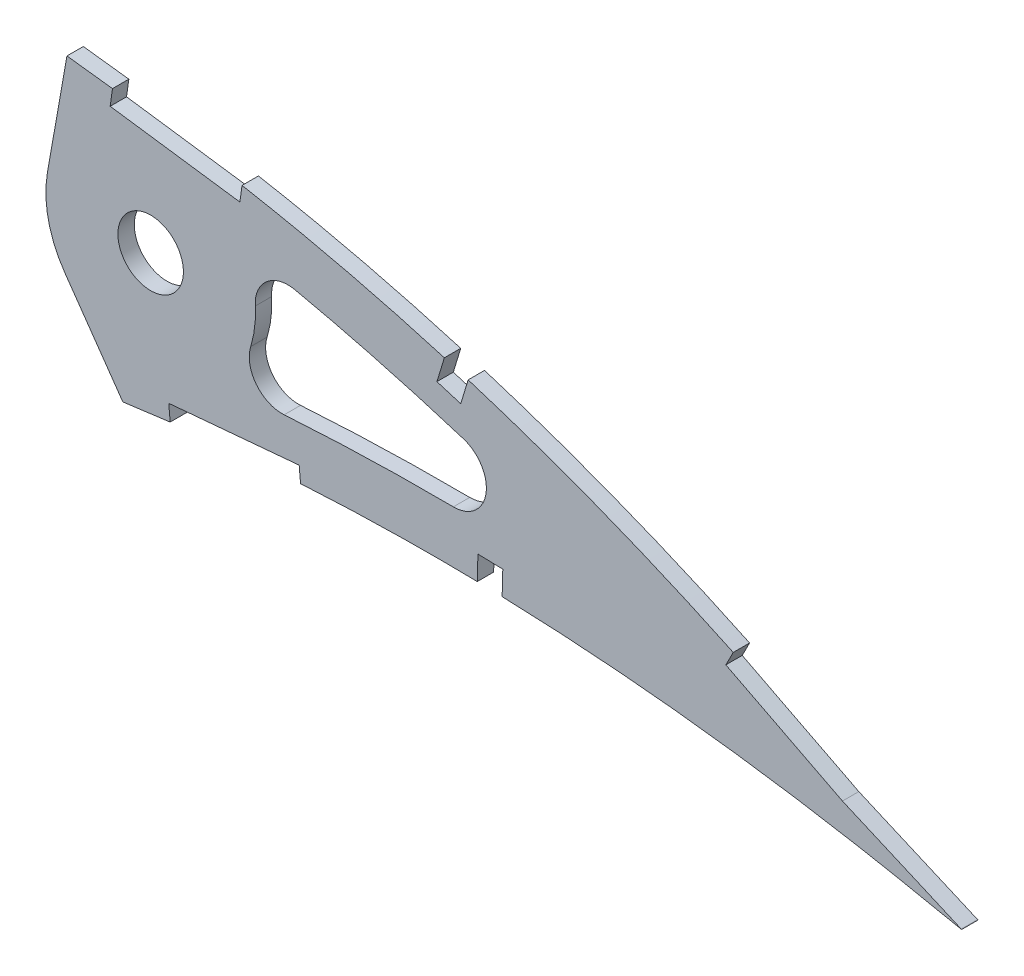
from build123d import *

# Parameters (mm, degrees)
BOSS_EXTRUDE1_DEPTH = 3.175
CUT_EXTRUDE3_DEPTH  = 7.62
CUT_EXTRUDE4_DEPTH  = 7.62
FILLET1_R           = 6.35


with BuildPart() as part:
    # Sketch1 → Boss-Extrude1 (new body)
    with BuildSketch(Plane.XY):
        with BuildLine():
            Line((519.580178516, -0.811051185), (524.404942797, -1.768650656))
            Line((524.404942797, -1.768650656), (520.229019484, 0.811051185))
            add(Edge.make_bspline(
                [(520.229019484, 0.811051185), (520.189166605, 0.835670541), (520.029909792, 0.934052399), (519.671075297, 1.154156729), (519.073541109, 1.52075127), (518.237045599, 2.031290225), (517.162238007, 2.684417324), (515.848577801, 3.475559373), (514.296885216, 4.402146321), (512.507535633, 5.459795421), (510.480712337, 6.64355473), (508.21718701, 7.948628257), (505.717156954, 9.367627965), (502.981590452, 10.894755239), (500.011426026, 12.522747531), (496.807225449, 14.244251548), (493.37013628, 16.050511122), (489.701477824, 17.933756977), (485.801919013, 19.88358962), (481.673298347, 21.891894303), (477.316991217, 23.948657398), (472.734484625, 26.042905917), (467.928411224, 28.166102482), (462.900099753, 30.30504754), (457.652415647, 32.45047346), (452.187593096, 34.590170691), (446.508867721, 36.714394111), (440.618430338, 38.809382682), (434.52068427, 40.865980983), (428.218587641, 42.870829), (421.71664718, 44.813038248), (415.018640596, 46.680016502), (408.130151416, 48.4621889), (401.05554842, 50.146576673), (393.800827801, 51.721905645), (386.37175624, 53.178690862), (378.7745642, 54.502388693), (371.03030434, 55.691966852), (363.263579962, 56.681494561), (355.512835044, 57.651994424), (347.773632806, 58.563690257), (339.939841334, 59.436765181), (332.018997168, 60.266303487), (324.018957152, 61.049711288), (315.947820171, 61.783607472), (307.813973652, 62.465839869), (299.625288266, 63.092542591), (291.390398495, 63.662750235), (283.117445562, 64.171449818), (274.815241205, 64.618259557), (266.492213302, 65.000063177), (258.157023363, 65.314229919), (249.818522106, 65.558863312), (241.485365181, 65.731619671), (233.166575282, 65.831412809), (224.870805251, 65.855515939), (216.607073574, 65.803497941), (208.384033719, 65.673572684), (200.210713382, 65.463961556), (192.095777843, 65.174273359), (184.048002143, 64.804633746), (176.076197788, 64.351947189), (168.189012741, 63.819098613), (160.39523005, 63.203849575), (152.703412853, 62.5060365), (145.121622257, 61.728568125), (137.65829938, 60.86932984), (130.321442651, 59.930766435), (123.119077117, 58.914718085), (116.059284027, 57.820631377), (109.149625996, 56.651666482), (102.397560522, 55.409019412), (95.81023125, 54.096333304), (89.394810054, 52.713950514), (83.158087983, 51.266017865), (77.106546628, 49.75505799), (71.246691254, 48.18383703), (65.58446207, 46.556125144), (60.125584795, 44.875615234), (54.876423204, 43.144153764), (49.840944503, 41.368305654), (45.025334256, 39.549331576), (40.433281375, 37.692835265), (36.070167381, 35.80135162), (31.939251719, 33.880646801), (28.045209615, 31.932907511), (24.39081638, 29.963590665), (20.979740738, 27.975715944), (17.815266227, 25.972975661), (14.898722839, 23.96044987), (12.234131686, 21.939401784), (9.822408113, 19.914938493), (7.665078309, 17.890142748), (5.765226023, 15.866409302), (4.122782784, 13.847302025), (2.739901149, 11.834419923), (1.61682102, 9.829667672), (0.75608259, 7.834501578), (0.156832386, 5.85004365), (-0.171193188, 3.879222922), (-0.252840734, 1.920459398), (-0.084154315, 0.639196632), (0, 0)],
                knots=[0, 0, 0, 0, 0.00025409, 0.001015373, 0.002283359, 0.004056577, 0.006330982, 0.009105275, 0.012374489, 0.016134023, 0.02037966, 0.025105976, 0.030306237, 0.035972206, 0.042099522, 0.048678064, 0.055701664, 0.063160184, 0.071045824, 0.079349826, 0.08806291, 0.097175757, 0.106678112, 0.116561573, 0.126814276, 0.1374283, 0.148393618, 0.15969976, 0.171338126, 0.183297699, 0.195569604, 0.208143556, 0.221011593, 0.234161831, 0.24758745, 0.261276822, 0.27522271, 0.289414144, 0.3037712, 0.317689227, 0.331784111, 0.346039677, 0.36044387, 0.374982721, 0.389640455, 0.404403317, 0.419256601, 0.434186749, 0.449177265, 0.464214782, 0.479284009, 0.49436974, 0.509457833, 0.524532346, 0.53957932, 0.554582984, 0.569529546, 0.584403417, 0.599190992, 0.613876838, 0.628447475, 0.642888675, 0.657186054, 0.671325546, 0.685294014, 0.699078147, 0.712665095, 0.726042645, 0.739197713, 0.752117586, 0.764792042, 0.777208152, 0.789355685, 0.80122396, 0.812803686, 0.824082909, 0.835054602, 0.845709571, 0.856037853, 0.866033834, 0.875688843, 0.884997719, 0.893953426, 0.902552897, 0.910789386, 0.918660734, 0.926166253, 0.933302626, 0.94007122, 0.94647478, 0.952517526, 0.958204819, 0.963546652, 0.9685566, 0.973249913, 0.977651041, 0.981787043, 0.985694226, 0.989415109, 0.993001157, 0.996508416, 1, 1, 1, 1], degree=3))
            add(Edge.make_bspline(
                [(0, 0), (0.133592971, -0.630647919), (0.401392883, -1.8948421), (1.12897029, -3.714757932), (2.091156676, -5.464224213), (3.308146123, -7.138593951), (4.771846833, -8.737409521), (6.479026026, -10.262333902), (8.42800953, -11.712547121), (10.616246406, -13.087389262), (13.040557967, -14.388319695), (15.69821927, -15.614529628), (18.58680706, -16.765635887), (21.703174164, -17.840099654), (25.043510698, -18.839557444), (28.604640883, -19.761573512), (32.382515332, -20.607436647), (36.373500457, -21.374987622), (40.573247311, -22.065006311), (44.977392966, -22.677106427), (49.581416855, -23.211670923), (54.380802091, -23.667578066), (59.370801609, -24.045808466), (64.546441805, -24.346612989), (69.902698778, -24.570945614), (75.434441794, -24.717953346), (81.136253147, -24.789928223), (87.002979994, -24.787950681), (93.028883282, -24.711491768), (99.208815464, -24.564775433), (105.536846201, -24.346872236), (112.007262561, -24.060419153), (118.614228145, -23.708298892), (125.351817225, -23.291705179), (132.214100493, -22.812484346), (139.195119589, -22.274479418), (146.288532921, -21.679032497), (153.488154076, -21.029614162), (160.787609185, -20.329475604), (168.180591644, -19.580832593), (175.660575836, -18.787206853), (183.220899465, -17.951170059), (190.855131019, -17.077182461), (198.556296664, -16.166825422), (206.317884213, -15.225296547), (214.132591981, -14.254394805), (221.993885293, -13.257859815), (229.894693671, -12.240383742), (237.827620604, -11.201850487), (245.785993956, -10.149659277), (253.762138918, -9.082943465), (261.749112783, -8.007189221), (269.739522148, -6.925740253), (277.725584215, -5.838929488), (285.70027901, -4.751260828), (293.656208576, -3.665720235), (301.585579958, -2.582406874), (309.481219182, -1.506705212), (317.335175518, -0.438483792), (325.140206955, 0.620091626), (332.888833934, 1.665861231), (340.573746099, 2.697505345), (348.187015915, 3.714371056), (355.720983847, 4.716840325), (363.055280122, 5.674485749), (370.170740115, 6.638302095), (377.091341637, 7.428417974), (383.925772848, 8.102810237), (390.681133097, 8.655718896), (397.349310673, 9.095098533), (403.922665289, 9.424088714), (410.393362863, 9.647282626), (416.753229966, 9.771301523), (422.994322965, 9.799292754), (429.108122993, 9.740182902), (435.086678505, 9.598736647), (440.921645401, 9.381302955), (446.604883368, 9.095217537), (452.128319892, 8.748279397), (457.483662622, 8.34560601), (462.663449177, 7.896598156), (467.65968785, 7.407828642), (472.464706853, 6.884881883), (477.071494939, 6.338715544), (481.472678479, 5.77292572), (485.661637464, 5.196810252), (489.631628754, 4.616207627), (493.376364947, 4.038530197), (496.889962423, 3.469289139), (500.16674573, 2.91603967), (503.201581909, 2.38395084), (505.989204715, 1.878219093), (508.525746868, 1.40522509), (510.806198597, 0.967318665), (512.827510034, 0.571716412), (514.585922757, 0.220164109), (516.078859088, -0.082385429), (517.303711765, -0.334738039), (518.258620558, -0.532751237), (518.941699265, -0.676741413), (519.352209069, -0.762422848), (519.534603778, -0.801329602), (519.580178516, -0.811051185)],
                knots=[0, 0, 0, 0, 0.003638255, 0.007293231, 0.011028136, 0.014901081, 0.018963272, 0.023258475, 0.027820626, 0.032679082, 0.03785316, 0.043361875, 0.049214679, 0.055422346, 0.061988786, 0.068918036, 0.076211157, 0.083868392, 0.091887411, 0.100265912, 0.108999867, 0.118084529, 0.127514843, 0.13728527, 0.147387917, 0.157816481, 0.168563473, 0.179619128, 0.190977373, 0.202626974, 0.214560478, 0.226767249, 0.239236417, 0.251959004, 0.264923894, 0.278119703, 0.291536035, 0.30516028, 0.318980685, 0.332985499, 0.34716279, 0.361498603, 0.375980747, 0.390597192, 0.405332593, 0.420174823, 0.435109533, 0.450124276, 0.465203068, 0.480333154, 0.495500583, 0.510689775, 0.525887334, 0.541078314, 0.556247233, 0.571381784, 0.586466041, 0.601484516, 0.616424329, 0.631269422, 0.646006524, 0.660620684, 0.675098188, 0.689422858, 0.703581825, 0.716907564, 0.730009274, 0.742952128, 0.755725558, 0.768319952, 0.780724337, 0.792926529, 0.804916041, 0.816679084, 0.828203524, 0.8394749, 0.850481359, 0.861207697, 0.871639326, 0.881763414, 0.891563605, 0.901027364, 0.910138977, 0.918883976, 0.927249278, 0.935221104, 0.942784739, 0.949928188, 0.956638464, 0.962904203, 0.968712287, 0.974054485, 0.978918432, 0.983297219, 0.987180246, 0.990560674, 0.993433357, 0.995790625, 0.997629587, 0.998945816, 0.999736592, 1, 1, 1, 1], degree=3))
        make_face()
    extrude(amount=BOSS_EXTRUDE1_DEPTH)

    # Sketch4 → Cut-Extrude3 (cut)
    with BuildSketch(Plane(origin=(0, 0, 0), x_dir=(-1, 0, 0), z_dir=(0, 0, -1))):
        with BuildLine():
            Line((-349.14248935, 48.169354496), (-347.130907312, 36.761105856))
            ThreePointArc((-347.130907312, 36.761105856), (-346.899524588, 35.003579579), (-346.822200854, 33.232574886))
            ThreePointArc((-346.822200854, 33.232574886), (-347.762672414, 27.12223304), (-350.497031314, 21.577501699))
            Line((-350.497031314, 21.577501699), (-355.179580356, 14.890128618))
            add(Edge.make_bspline(
                [(-10.021983668, 1.718504447), (-10.07412361, 1.477650445), (-10.114944509, 1.303174971), (-10.156548889, 1.141436943), (-10.167021522, 1.104153089), (-10.176316559, 1.072542508), (-10.178069379, 1.066836035), (-10.183484597, 1.049711185), (-10.186673858, 1.039927229), (-10.205238412, 0.98502642), (-10.228571307, 0.921908681), (-10.27906945, 0.80173784), (-10.298464439, 0.7574435), (-10.342612759, 0.661010339), (-10.367571751, 0.608494082), (-10.442823867, 0.45606075), (-10.495986254, 0.355803747), (-10.608102234, 0.158407972), (-10.666162883, 0.06265551), (-10.854968465, -0.229090809), (-11.00643436, -0.438409454), (-11.537771942, -1.093588654), (-11.997135293, -1.567704333), (-13.099028095, -2.52560338), (-13.741234272, -3.010007667), (-15.170231039, -3.956772652), (-15.958792546, -4.420759041), (-17.636020893, -5.30935855), (-18.526216751, -5.735132845), (-21.309408713, -6.950344824), (-23.307276982, -7.674934635), (-27.46702649, -8.97576354), (-29.622936527, -9.549686743), (-34.031579145, -10.575277046), (-36.279538408, -11.025153664), (-40.839010815, -11.824269496), (-43.147104248, -12.172849285), (-47.803539587, -12.786210538), (-50.150083972, -13.050814849), (-57.229184321, -13.737294833), (-62.003016189, -14.054069855), (-71.598509018, -14.480928375), (-76.421961843, -14.589122052), (-83.681580342, -14.632442814), (-86.103710065, -14.626756009), (-90.955097909, -14.578941965), (-93.385559609, -14.537119349), (-100.67932715, -14.364677341), (-105.548006485, -14.185375883), (-120.177304443, -13.493946775), (-129.947568603, -12.830040027), (-149.500900247, -11.230052761), (-159.28699099, -10.293590446), (-178.862979206, -8.239223166), (-188.653155316, -7.120306209), (-203.345768331, -5.354247594), (-208.242397067, -4.751052701), (-218.038698444, -3.520719007), (-222.939495496, -2.894332575), (-232.735865431, -1.624265185), (-237.638546286, -0.979500709), (-247.439293316, 0.320232313), (-252.34040524, 0.977351243), (-262.147002187, 2.298643123), (-267.049997176, 2.962506366), (-276.85767651, 4.296404336), (-281.76413014, 4.965872948), (-291.576776525, 6.304693949), (-296.482463455, 6.975228249), (-306.300679591, 8.314190148), (-311.208735298, 8.982245452), (-325.937797656, 10.98262524), (-335.765990201, 12.306839554), (-348.046657919, 13.945065226), (-350.503930711, 14.272529112), (-353.703483298, 14.695680718), (-354.441892389, 14.793034628), (-355.179580356, 14.890128618)],
                knots=[0, 0, 0, 0, 0.001953125, 0.001953125, 0.002929688, 0.002929688, 0.003417969, 0.003417969, 0.00390625, 0.00390625, 0.005859375, 0.005859375, 0.006835938, 0.006835938, 0.0078125, 0.0078125, 0.009765625, 0.009765625, 0.01171875, 0.01171875, 0.015625, 0.015625, 0.0234375, 0.0234375, 0.03125, 0.03125, 0.0390625, 0.0390625, 0.046875, 0.046875, 0.0625, 0.0625, 0.078125, 0.078125, 0.09375, 0.09375, 0.109375, 0.109375, 0.125, 0.125, 0.15625, 0.15625, 0.1875, 0.1875, 0.203125, 0.203125, 0.21875, 0.21875, 0.25, 0.25, 0.3125, 0.3125, 0.375, 0.375, 0.4375, 0.4375, 0.46875, 0.46875, 0.5, 0.5, 0.53125, 0.53125, 0.5625, 0.5625, 0.59375, 0.59375, 0.625, 0.625, 0.65625, 0.65625, 0.6875, 0.6875, 0.75, 0.75, 0.765625, 0.765625, 0.770309007, 0.770309007, 0.770309007, 0.770309007], degree=3))
            add(Edge.make_bspline(
                [(-349.14248935, 48.169354496), (-346.795088799, 48.443461283), (-344.445266437, 48.710791614), (-339.547708643, 49.253693934), (-336.999317609, 49.527914022), (-329.351218513, 50.325591781), (-324.249629568, 50.824187172), (-308.936798872, 52.217367234), (-298.717604439, 53.010707627), (-278.271746609, 54.303919673), (-268.04058752, 54.805738268), (-247.580126149, 55.491327017), (-237.350101584, 55.675458898), (-216.900448668, 55.69215602), (-206.683126571, 55.52564041), (-191.377917358, 54.978478925), (-186.2811734, 54.747225516), (-176.097881874, 54.177019905), (-171.009883782, 53.839581001), (-160.853325764, 53.050443965), (-155.781406433, 52.598034279), (-145.657356086, 51.571992269), (-140.607230814, 50.997094398), (-125.489247663, 49.071048015), (-115.464585248, 47.521419143), (-100.554676791, 44.706390499), (-95.609568485, 43.686963586), (-85.777014674, 41.462020045), (-80.892152382, 40.257818542), (-71.207221082, 37.636651206), (-66.406776713, 36.220917836), (-59.302413791, 33.90898455), (-56.947363109, 33.106291256), (-52.282107957, 31.434331217), (-49.969322239, 30.563571343), (-45.392720502, 28.745833214), (-43.131848477, 27.799594329), (-38.671512861, 25.819641246), (-36.476017636, 24.788163994), (-32.175786858, 22.628129157), (-30.06919395, 21.499499767), (-27.012454773, 19.728422083), (-26.01030714, 19.124661313), (-24.046433441, 17.888999014), (-23.083087936, 17.256148879), (-21.212769006, 15.965886334), (-20.304850458, 15.30761594), (-18.553368516, 13.962900236), (-17.709326175, 13.276269337), (-16.108143733, 11.882352161), (-15.351929118, 11.17596838), (-14.304534439, 10.110877651), (-13.970137373, 9.755237813), (-13.332516445, 9.043077516), (-13.02962733, 8.686953168), (-12.180304935, 7.629928767), (-11.689567714, 6.934793852), (-10.890562918, 5.612793643), (-10.587398477, 4.993614778), (-10.268976897, 4.158008466), (-10.186143047, 3.89687765), (-10.09533528, 3.545881825), (-10.070664667, 3.436625129), (-10.026694338, 3.210393083), (-10.008058479, 3.095951038), (-9.977689614, 2.864928598), (-9.965765536, 2.743795853), (-9.952900238, 2.554662515), (-9.951205484, 2.481144388), (-9.951588775, 2.417814084), (-9.951784603, 2.406570209), (-9.952306257, 2.386954058), (-9.952564773, 2.379980569), (-9.953821763, 2.353767727), (-9.955956606, 2.318014253), (-9.969807564, 2.15543948), (-9.989590405, 1.973346258), (-10.021983668, 1.718504447)],
                knots=[0.251217482, 0.251217482, 0.251217482, 0.251217482, 0.265625, 0.265625, 0.28125, 0.28125, 0.3125, 0.3125, 0.375, 0.375, 0.4375, 0.4375, 0.5, 0.5, 0.5625, 0.5625, 0.59375, 0.59375, 0.625, 0.625, 0.65625, 0.65625, 0.6875, 0.6875, 0.75, 0.75, 0.78125, 0.78125, 0.8125, 0.8125, 0.84375, 0.84375, 0.859375, 0.859375, 0.875, 0.875, 0.890625, 0.890625, 0.90625, 0.90625, 0.921875, 0.921875, 0.9296875, 0.9296875, 0.9375, 0.9375, 0.9453125, 0.9453125, 0.953125, 0.953125, 0.9609375, 0.9609375, 0.96484375, 0.96484375, 0.96875, 0.96875, 0.9765625, 0.9765625, 0.984375, 0.984375, 0.98828125, 0.98828125, 0.990234375, 0.990234375, 0.9921875, 0.9921875, 0.994140625, 0.994140625, 0.99609375, 0.99609375, 0.996582031, 0.996582031, 0.997070313, 0.997070313, 0.998046875, 0.998046875, 1, 1, 1, 1], degree=3))
        make_face()
        with BuildLine():
            ThreePointArc((-360.792200854, 33.232574886), (-367.142200854, 39.582574886), (-373.492200854, 33.232574886))
            ThreePointArc((-373.492200854, 33.232574886), (-367.142200854, 26.882574886), (-360.792200854, 33.232574886))
        make_face()
        with BuildLine():
            Line((-350.909730833, 58.191878985), (-349.14248935, 48.169354496))
            add(Edge.make_bspline(
                [(-349.14248935, 48.169354496), (-346.795088799, 48.443461283), (-344.445266437, 48.710791614), (-339.547708643, 49.253693934), (-336.999317609, 49.527914022), (-329.351218513, 50.325591781), (-324.249629568, 50.824187172), (-308.936798872, 52.217367234), (-298.717604439, 53.010707627), (-278.271746609, 54.303919673), (-268.04058752, 54.805738268), (-247.580126149, 55.491327017), (-237.350101584, 55.675458898), (-216.900448668, 55.69215602), (-206.683126571, 55.52564041), (-191.377917358, 54.978478925), (-186.2811734, 54.747225516), (-176.097881874, 54.177019905), (-171.009883782, 53.839581001), (-160.853325764, 53.050443965), (-155.781406433, 52.598034279), (-145.657356086, 51.571992269), (-140.607230814, 50.997094398), (-125.489247663, 49.071048015), (-115.464585248, 47.521419143), (-100.554676791, 44.706390499), (-95.609568485, 43.686963586), (-85.777014674, 41.462020045), (-80.892152382, 40.257818542), (-71.207221082, 37.636651206), (-66.406776713, 36.220917836), (-59.302413791, 33.90898455), (-56.947363109, 33.106291256), (-52.282107957, 31.434331217), (-49.969322239, 30.563571343), (-45.392720502, 28.745833214), (-43.131848477, 27.799594329), (-38.671512861, 25.819641246), (-36.476017636, 24.788163994), (-32.175786858, 22.628129157), (-30.06919395, 21.499499767), (-27.012454773, 19.728422083), (-26.01030714, 19.124661313), (-24.046433441, 17.888999014), (-23.083087936, 17.256148879), (-21.212769006, 15.965886334), (-20.304850458, 15.30761594), (-18.553368516, 13.962900236), (-17.709326175, 13.276269337), (-16.108143733, 11.882352161), (-15.351929118, 11.17596838), (-14.304534439, 10.110877651), (-13.970137373, 9.755237813), (-13.332516445, 9.043077516), (-13.02962733, 8.686953168), (-12.180304935, 7.629928767), (-11.689567714, 6.934793852), (-10.890562918, 5.612793643), (-10.587398477, 4.993614778), (-10.268976897, 4.158008466), (-10.186143047, 3.89687765), (-10.09533528, 3.545881825), (-10.070664667, 3.436625129), (-10.026694338, 3.210393083), (-10.008058479, 3.095951038), (-9.977689614, 2.864928598), (-9.965765536, 2.743795853), (-9.952900238, 2.554662515), (-9.951205484, 2.481144388), (-9.951588775, 2.417814084), (-9.951784603, 2.406570209), (-9.952306257, 2.386954058), (-9.952564773, 2.379980569), (-9.953821763, 2.353767727), (-9.955956606, 2.318014253), (-9.969807564, 2.15543948), (-9.989590405, 1.973346258), (-10.021983668, 1.718504447)],
                knots=[0.251217482, 0.251217482, 0.251217482, 0.251217482, 0.265625, 0.265625, 0.28125, 0.28125, 0.3125, 0.3125, 0.375, 0.375, 0.4375, 0.4375, 0.5, 0.5, 0.5625, 0.5625, 0.59375, 0.59375, 0.625, 0.625, 0.65625, 0.65625, 0.6875, 0.6875, 0.75, 0.75, 0.78125, 0.78125, 0.8125, 0.8125, 0.84375, 0.84375, 0.859375, 0.859375, 0.875, 0.875, 0.890625, 0.890625, 0.90625, 0.90625, 0.921875, 0.921875, 0.9296875, 0.9296875, 0.9375, 0.9375, 0.9453125, 0.9453125, 0.953125, 0.953125, 0.9609375, 0.9609375, 0.96484375, 0.96484375, 0.96875, 0.96875, 0.9765625, 0.9765625, 0.984375, 0.984375, 0.98828125, 0.98828125, 0.990234375, 0.990234375, 0.9921875, 0.9921875, 0.994140625, 0.994140625, 0.99609375, 0.99609375, 0.996582031, 0.996582031, 0.997070313, 0.997070313, 0.998046875, 0.998046875, 1, 1, 1, 1], degree=3))
            add(Edge.make_bspline(
                [(-7.716509218, 17.89881351), (-8.627577305, 8.933677844), (-9.635591183, 3.50339667), (-10.021983668, 1.718504447)],
                knots=[-0.014473987, -0.014473987, -0.014473987, -0.014473987, 0, 0, 0, 0], degree=3))
            add(Edge.make_bspline(
                [(-350.909730833, 58.191878985), (-349.87402552, 58.313335631), (-346.227461312, 58.736010846), (-339.939841334, 59.436765181), (-332.018997168, 60.266303487), (-324.018957152, 61.049711288), (-315.947820171, 61.783607472), (-307.813973652, 62.465839869), (-299.625288266, 63.092542591), (-291.390398495, 63.662750235), (-283.117445562, 64.171449818), (-274.815241205, 64.618259557), (-266.492213302, 65.000063177), (-258.157023363, 65.314229919), (-249.818522106, 65.558863312), (-241.485365181, 65.731619671), (-233.166575282, 65.831412809), (-224.870805251, 65.855515939), (-216.607073574, 65.803497941), (-208.384033719, 65.673572684), (-200.210713382, 65.463961556), (-192.095777843, 65.174273359), (-184.048002143, 64.804633746), (-176.076197788, 64.351947189), (-168.189012741, 63.819098613), (-160.39523005, 63.203849575), (-152.703412853, 62.5060365), (-145.121622257, 61.728568125), (-137.65829938, 60.86932984), (-130.321442651, 59.930766435), (-123.119077117, 58.914718085), (-116.059284027, 57.820631377), (-109.149625996, 56.651666482), (-102.397560522, 55.409019412), (-95.81023125, 54.096333304), (-89.394810054, 52.713950514), (-83.158087983, 51.266017865), (-77.106546628, 49.75505799), (-71.246691254, 48.18383703), (-65.58446207, 46.556125144), (-60.125584795, 44.875615234), (-54.876423204, 43.144153764), (-49.840944503, 41.368305654), (-45.025334256, 39.549331576), (-40.433281375, 37.692835265), (-36.070167381, 35.80135162), (-31.939251719, 33.880646801), (-28.045209615, 31.932907511), (-24.39081638, 29.963590665), (-20.979740738, 27.975715944), (-17.815266227, 25.972975661), (-14.898722839, 23.96044987), (-12.234131686, 21.939401784), (-9.848909513, 19.937184455), (-8.389426027, 18.569945978), (-7.716509217, 17.89881351)],
                knots=[0.326127798, 0.326127798, 0.326127798, 0.326127798, 0.331784111, 0.346039677, 0.36044387, 0.374982721, 0.389640455, 0.404403317, 0.419256601, 0.434186749, 0.449177265, 0.464214782, 0.479284009, 0.49436974, 0.509457833, 0.524532346, 0.53957932, 0.554582984, 0.569529546, 0.584403417, 0.599190992, 0.613876838, 0.628447475, 0.642888675, 0.657186054, 0.671325546, 0.685294014, 0.699078147, 0.712665095, 0.726042645, 0.739197713, 0.752117586, 0.764792042, 0.777208152, 0.789355685, 0.80122396, 0.812803686, 0.824082909, 0.835054602, 0.845709571, 0.856037853, 0.866033834, 0.875688843, 0.884997719, 0.893953426, 0.902552897, 0.910789386, 0.918660734, 0.926166253, 0.933302626, 0.94007122, 0.94647478, 0.952517526, 0.958204819, 0.963359057, 0.963359057, 0.963359057, 0.963359057], degree=3))
        make_face()
        with BuildLine():
            add(Edge.make_bspline(
                [(-10.021983668, 1.718504447), (-10.253419541, -0.102230211), (-11.128552571, -5.636405878), (-13.399217815, -14.533387864)],
                knots=[1, 1, 1, 1, 1.013954234, 1.013954234, 1.013954234, 1.013954234], degree=3))
            add(Edge.make_bspline(
                [(-10.021983668, 1.718504447), (-10.07412361, 1.477650445), (-10.114944509, 1.303174971), (-10.156548889, 1.141436943), (-10.167021522, 1.104153089), (-10.176316559, 1.072542508), (-10.178069379, 1.066836035), (-10.183484597, 1.049711185), (-10.186673858, 1.039927229), (-10.205238412, 0.98502642), (-10.228571307, 0.921908681), (-10.27906945, 0.80173784), (-10.298464439, 0.7574435), (-10.342612759, 0.661010339), (-10.367571751, 0.608494082), (-10.442823867, 0.45606075), (-10.495986254, 0.355803747), (-10.608102234, 0.158407972), (-10.666162883, 0.06265551), (-10.854968465, -0.229090809), (-11.00643436, -0.438409454), (-11.537771942, -1.093588654), (-11.997135293, -1.567704333), (-13.099028095, -2.52560338), (-13.741234272, -3.010007667), (-15.170231039, -3.956772652), (-15.958792546, -4.420759041), (-17.636020893, -5.30935855), (-18.526216751, -5.735132845), (-21.309408713, -6.950344824), (-23.307276982, -7.674934635), (-27.46702649, -8.97576354), (-29.622936527, -9.549686743), (-34.031579145, -10.575277046), (-36.279538408, -11.025153664), (-40.839010815, -11.824269496), (-43.147104248, -12.172849285), (-47.803539587, -12.786210538), (-50.150083972, -13.050814849), (-57.229184321, -13.737294833), (-62.003016189, -14.054069855), (-71.598509018, -14.480928375), (-76.421961843, -14.589122052), (-83.681580342, -14.632442814), (-86.103710065, -14.626756009), (-90.955097909, -14.578941965), (-93.385559609, -14.537119349), (-100.67932715, -14.364677341), (-105.548006485, -14.185375883), (-120.177304443, -13.493946775), (-129.947568603, -12.830040027), (-149.500900247, -11.230052761), (-159.28699099, -10.293590446), (-178.862979206, -8.239223166), (-188.653155316, -7.120306209), (-203.345768331, -5.354247594), (-208.242397067, -4.751052701), (-218.038698444, -3.520719007), (-222.939495496, -2.894332575), (-232.735865431, -1.624265185), (-237.638546286, -0.979500709), (-247.439293316, 0.320232313), (-252.34040524, 0.977351243), (-262.147002187, 2.298643123), (-267.049997176, 2.962506366), (-276.85767651, 4.296404336), (-281.76413014, 4.965872948), (-291.576776525, 6.304693949), (-296.482463455, 6.975228249), (-306.300679591, 8.314190148), (-311.208735298, 8.982245452), (-325.937797656, 10.98262524), (-335.765990201, 12.306839554), (-348.046657919, 13.945065226), (-350.503930711, 14.272529112), (-353.703483298, 14.695680718), (-354.441892389, 14.793034628), (-355.179580356, 14.890128618)],
                knots=[0, 0, 0, 0, 0.001953125, 0.001953125, 0.002929688, 0.002929688, 0.003417969, 0.003417969, 0.00390625, 0.00390625, 0.005859375, 0.005859375, 0.006835938, 0.006835938, 0.0078125, 0.0078125, 0.009765625, 0.009765625, 0.01171875, 0.01171875, 0.015625, 0.015625, 0.0234375, 0.0234375, 0.03125, 0.03125, 0.0390625, 0.0390625, 0.046875, 0.046875, 0.0625, 0.0625, 0.078125, 0.078125, 0.09375, 0.09375, 0.109375, 0.109375, 0.125, 0.125, 0.15625, 0.15625, 0.1875, 0.1875, 0.203125, 0.203125, 0.21875, 0.21875, 0.25, 0.25, 0.3125, 0.3125, 0.375, 0.375, 0.4375, 0.4375, 0.46875, 0.46875, 0.5, 0.5, 0.53125, 0.53125, 0.5625, 0.5625, 0.59375, 0.59375, 0.625, 0.625, 0.65625, 0.65625, 0.6875, 0.6875, 0.75, 0.75, 0.765625, 0.765625, 0.770309007, 0.770309007, 0.770309007, 0.770309007], degree=3))
            Line((-355.179580356, 14.890128618), (-361.749554482, 5.507233166))
            add(Edge.make_bspline(
                [(-13.399217815, -14.533387864), (-14.141861653, -14.89580716), (-15.836050944, -15.669455742), (-18.58680706, -16.765635887), (-21.703174164, -17.840099654), (-25.043510698, -18.839557444), (-28.604640883, -19.761573512), (-32.382515332, -20.607436647), (-36.373500457, -21.374987622), (-40.573247311, -22.065006311), (-44.977392966, -22.677106427), (-49.581416855, -23.211670923), (-54.380802091, -23.667578066), (-59.370801609, -24.045808466), (-64.546441805, -24.346612989), (-69.902698778, -24.570945614), (-75.434441794, -24.717953346), (-81.136253147, -24.789928223), (-87.002979994, -24.787950681), (-93.028883282, -24.711491768), (-99.208815464, -24.564775433), (-105.536846201, -24.346872236), (-112.007262561, -24.060419153), (-118.614228145, -23.708298892), (-125.351817225, -23.291705179), (-132.214100493, -22.812484346), (-139.195119589, -22.274479418), (-146.288532921, -21.679032497), (-153.488154076, -21.029614162), (-160.787609185, -20.329475604), (-168.180591644, -19.580832593), (-175.660575836, -18.787206853), (-183.220899465, -17.951170059), (-190.855131019, -17.077182461), (-198.556296664, -16.166825422), (-206.317884213, -15.225296547), (-214.132591981, -14.254394805), (-221.993885293, -13.257859815), (-229.894693671, -12.240383742), (-237.827620604, -11.201850487), (-245.785993956, -10.149659277), (-253.762138918, -9.082943465), (-261.749112783, -8.007189221), (-269.739522148, -6.925740253), (-277.725584215, -5.838929488), (-285.70027901, -4.751260828), (-293.656208576, -3.665720235), (-301.585579958, -2.582406874), (-309.481219182, -1.506705212), (-317.335175518, -0.438483792), (-325.140206955, 0.620091626), (-332.888833934, 1.665861231), (-340.573746099, 2.697505345), (-348.187015915, 3.714371056), (-355.23730571, 4.652482144), (-359.750002253, 5.242796176), (-361.749554482, 5.507233166)],
                knots=[0.03869149, 0.03869149, 0.03869149, 0.03869149, 0.043361875, 0.049214679, 0.055422346, 0.061988786, 0.068918036, 0.076211157, 0.083868392, 0.091887411, 0.100265912, 0.108999867, 0.118084529, 0.127514843, 0.13728527, 0.147387917, 0.157816481, 0.168563473, 0.179619128, 0.190977373, 0.202626974, 0.214560478, 0.226767249, 0.239236417, 0.251959004, 0.264923894, 0.278119703, 0.291536035, 0.30516028, 0.318980685, 0.332985499, 0.34716279, 0.361498603, 0.375980747, 0.390597192, 0.405332593, 0.420174823, 0.435109533, 0.450124276, 0.465203068, 0.480333154, 0.495500583, 0.510689775, 0.525887334, 0.541078314, 0.556247233, 0.571381784, 0.586466041, 0.601484516, 0.616424329, 0.631269422, 0.646006524, 0.660620684, 0.675098188, 0.689422858, 0.700823734, 0.700823734, 0.700823734, 0.700823734], degree=3))
        make_face()
        with BuildLine():
            add(Edge.make_bspline(
                [(-7.716509218, 17.89881351), (-8.627577305, 8.933677844), (-9.635591183, 3.50339667), (-10.021983668, 1.718504447)],
                knots=[-0.014473987, -0.014473987, -0.014473987, -0.014473987, 0, 0, 0, 0], degree=3))
            add(Edge.make_bspline(
                [(-10.021983668, 1.718504447), (-10.253419541, -0.102230211), (-11.128552571, -5.636405878), (-13.399217815, -14.533387864)],
                knots=[1, 1, 1, 1, 1.013954234, 1.013954234, 1.013954234, 1.013954234], degree=3))
            add(Edge.make_bspline(
                [(0, 0), (-0.133592971, -0.630647919), (-0.401392883, -1.8948421), (-1.12897029, -3.714757932), (-2.091156676, -5.464224213), (-3.308146123, -7.138593951), (-4.771846833, -8.737409521), (-6.479026026, -10.262333902), (-8.42800953, -11.712547121), (-10.616246406, -13.087389262), (-12.31201499, -13.997370056), (-13.265913859, -14.4683339), (-13.399217815, -14.533387864)],
                knots=[0, 0, 0, 0, 0.003638255, 0.007293231, 0.011028136, 0.014901081, 0.018963272, 0.023258475, 0.027820626, 0.032679082, 0.03785316, 0.03869149, 0.03869149, 0.03869149, 0.03869149], degree=3))
            add(Edge.make_bspline(
                [(-7.716509217, 17.89881351), (-7.692017493, 17.874386729), (-7.014215615, 17.19684011), (-5.765226023, 15.866409302), (-4.122782784, 13.847302025), (-2.739901149, 11.834419923), (-1.61682102, 9.829667672), (-0.75608259, 7.834501578), (-0.156832386, 5.85004365), (0.171193188, 3.879222922), (0.252840734, 1.920459398), (0.084154315, 0.639196632), (0, 0)],
                knots=[0.963359057, 0.963359057, 0.963359057, 0.963359057, 0.963546652, 0.9685566, 0.973249913, 0.977651041, 0.981787043, 0.985694226, 0.989415109, 0.993001157, 0.996508416, 1, 1, 1, 1], degree=3))
        make_face()
        with BuildLine():
            ThreePointArc((-387.462200854, 33.232574886), (-386.814278928, 38.322932855), (-384.911832325, 43.088669314))
            add(Edge.make_bspline(
                [(-466.381536904, 17.739023349), (-464.077384324, 18.757444743), (-461.765249862, 19.752184237), (-457.118450141, 21.69708064), (-454.786398451, 22.646347671), (-450.10385626, 24.497815956), (-447.75240197, 25.400700405), (-443.035237053, 27.157945334), (-440.669001058, 28.012063218), (-428.788452876, 32.165169282), (-419.157290014, 35.099148044), (-404.551556817, 38.892321547), (-399.659263176, 40.054506405), (-392.285300647, 41.643217334), (-389.821414131, 42.147253508), (-386.540289083, 42.782388067), (-385.726343584, 42.936953373), (-384.911832325, 43.088669314)],
                knots=[0, 0, 0, 0, 0.015625, 0.015625, 0.03125, 0.03125, 0.046875, 0.046875, 0.0625, 0.0625, 0.125, 0.125, 0.15625, 0.15625, 0.171875, 0.171875, 0.177026295, 0.177026295, 0.177026295, 0.177026295], degree=3))
            add(Edge.make_bspline(
                [(-380.561771086, 17.974215381), (-381.333926082, 18.048413309), (-382.106576309, 18.12056427), (-385.407153236, 18.419587346), (-387.935449623, 18.625484759), (-395.52207913, 19.176670751), (-400.588304878, 19.455243016), (-408.190000105, 19.738575875), (-410.723661334, 19.810841317), (-415.79361755, 19.911332927), (-418.330137741, 19.939186396), (-425.933912422, 19.956601518), (-431.001864577, 19.881497473), (-441.132423715, 19.557892286), (-446.190669671, 19.310202102), (-453.772484524, 18.813875302), (-456.298225615, 18.627115644), (-461.342325377, 18.213449628), (-463.862465791, 17.986463508), (-466.381536904, 17.739023349)],
                knots=[0.823343682, 0.823343682, 0.823343682, 0.823343682, 0.828125, 0.828125, 0.84375, 0.84375, 0.875, 0.875, 0.890625, 0.890625, 0.90625, 0.90625, 0.9375, 0.9375, 0.96875, 0.96875, 0.984375, 0.984375, 1, 1, 1, 1], degree=3))
            ThreePointArc((-380.561771086, 17.974215381), (-385.656898625, 24.859500992), (-387.462200854, 33.232574886))
        make_face()
    extrude(amount=-CUT_EXTRUDE3_DEPTH, mode=Mode.SUBTRACT)

    # Sketch5 → Cut-Extrude4 (cut)
    with BuildSketch(Plane.XY.offset(3.175)):
        Polygon((430.47640415, 9.564371746), (435.299189247, 9.436333747), (435.427227246, 14.259118844), (430.604442149, 14.387156843), align=None)
        Polygon((370.652391531, 9.724495467), (370.934324926, 6.563166846), (396.224953897, 8.818634007), (395.943020502, 11.979962629), align=None)
        Polygon((359.730550578, 57.0740322), (360.354958806, 61.547717189), (384.883001855, 55.31872337), (384.883001855, 53.56341454), (384.444174647, 50.419358131), (359.291723371, 53.929975791), align=None)
        Polygon((424.062053567, 43.982510938), (424.549022553, 45.583034765), (428.891030458, 43.280386749), (428.677404958, 42.578262561), (427.273156581, 37.962911171), (422.657805191, 39.367159548), align=None)
        Polygon((480.124414871, 22.640333852), (478.679160871, 19.81341576), (501.294505608, 8.251383756), (524.603235395, -1.841205854), (525.864809096, 1.072385369), (502.648511375, 11.124952253), align=None)
    extrude(amount=-CUT_EXTRUDE4_DEPTH, mode=Mode.SUBTRACT)


with BuildPart() as body_2:
    # of the pieces the cut leaves, the one that is kept (cut_extrude4_keep)
    add(part.part.solids().sort_by_distance((519.580178516, -0.811051185, 0))[0])

    # Fillet1
    fillet1_edges = [body_2.edges().sort_by_distance(p)[0] for p in [
        (466.381536904, 17.739023349, 1.5875),
        (380.561771086, 17.974215381, 1.5875),
        (384.911832325, 43.088669314, 1.5875),
    ]]
    fillet(fillet1_edges, radius=FILLET1_R)


solid = body_2.part
